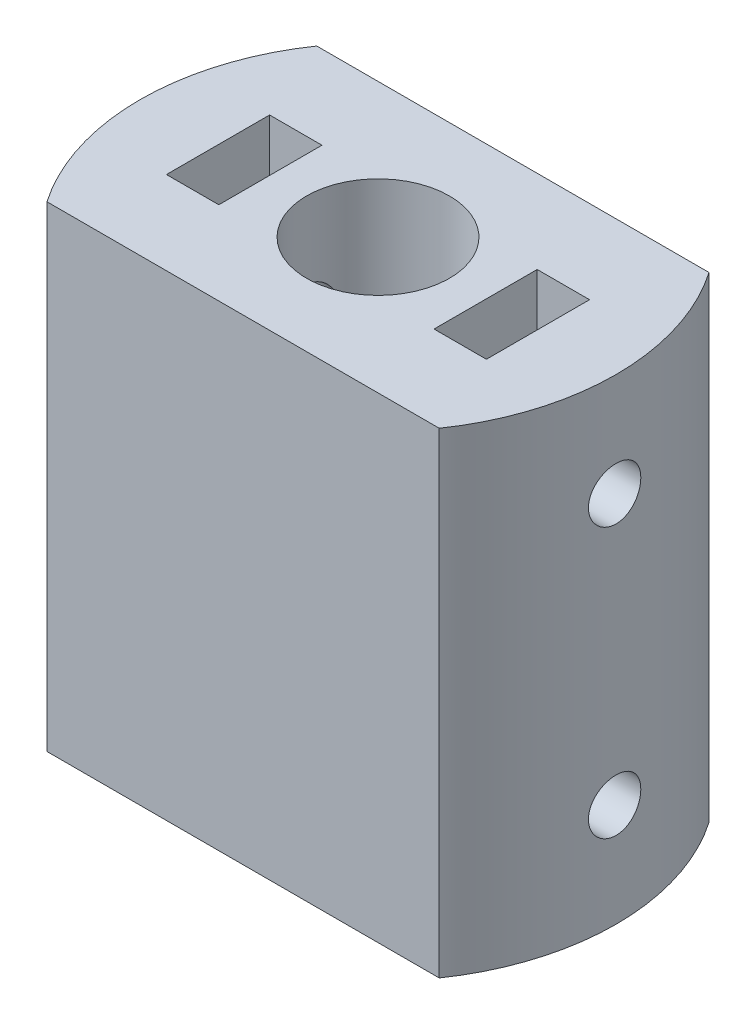
from build123d import *

# Parameters (mm, degrees)
ESBO_O2_W                  = 3.3
ESBO_O2_H                  = 6.5
CORTE_EXTRUS_O1_DEPTH      = 13
CORTE_EXTRUS_O2_START      = -30
ESBO_O2_2_W                = 3.3
ESBO_O2_2_H                = 6.5
CORTE_EXTRUS_O2_DEPTH      = 13
CORTE_EXTRUS_O4_START      = 15
ESBO_O3_R                  = 1.65
CORTE_EXTRUS_O4_DEPTH      = 37.780782806
ESBO_O4_W                  = 59.68713318
ESBO_O4_H                  = 37
ESBO_O4_W_2                = 39.68713318
ESBO_O4_H_2                = 17
CORTE_EXTRUS_O_FINA1_DEPTH = 33


with BuildPart() as part:
    # Esboço1 → Revolução1 (revolve)
    with BuildSketch(Plane.XY):
        Polygon((4.5, 30), (15, 30), (15, 0), (3.25, 0), (3.25, 15), (4.5, 15), align=None)
    revolve(axis=Axis((0, 0, 0), (0, 1, 0)))

    # Esboço2 → Corte-extrusão1 (cut)
    with BuildSketch(Plane.XZ):
        with Locations((8.430782806, 0)):
            Rectangle(ESBO_O2_W, ESBO_O2_H)
        with Locations((-8.430782806, 0)):
            Rectangle(ESBO_O2_W, ESBO_O2_H)
    extrude(amount=-CORTE_EXTRUS_O1_DEPTH, mode=Mode.SUBTRACT)

    # Esboço2<2> → Corte-extrusão2 (cut)
    with BuildSketch(Plane.XZ.offset(CORTE_EXTRUS_O2_START)):
        with Locations((8.430782806, 0)):
            Rectangle(ESBO_O2_2_W, ESBO_O2_2_H)
        with Locations((-8.430782806, 0)):
            Rectangle(ESBO_O2_2_W, ESBO_O2_2_H)
    extrude(amount=CORTE_EXTRUS_O2_DEPTH, mode=Mode.SUBTRACT)

    # Esboço3 → Corte-extrusão4 (cut, through all)
    with BuildSketch(Plane(origin=(6.780782806, 0, 0), x_dir=(0, 0, -1), z_dir=(1, 0, 0)).offset(CORTE_EXTRUS_O4_START)):
        with Locations((0, 23.5)):
            Circle(ESBO_O3_R)
        with Locations((0, 6.5)):
            Circle(ESBO_O3_R)
    extrude(amount=-CORTE_EXTRUS_O4_DEPTH, mode=Mode.SUBTRACT)

    # Esboço4 → Corte-Extrusão-Fina1 (cut)
    with BuildSketch(Plane.XZ):
        Rectangle(ESBO_O4_W, ESBO_O4_H)
        Rectangle(ESBO_O4_W_2, ESBO_O4_H_2, mode=Mode.SUBTRACT)
    extrude(amount=-CORTE_EXTRUS_O_FINA1_DEPTH, mode=Mode.SUBTRACT)


solid = part.part
